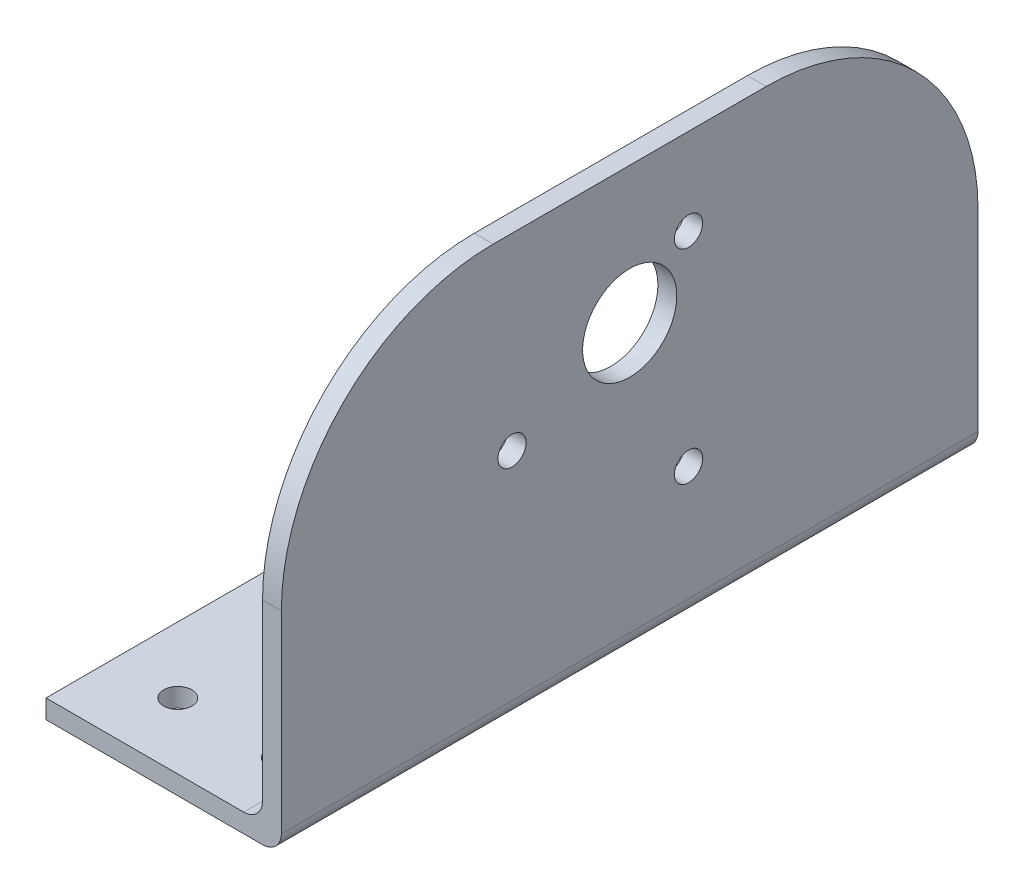
from build123d import *

# Parameters (mm, degrees)
BOSS_EXTRUDE1_DEPTH = 2
SKETCH2_W           = 74
SKETCH2_H           = 2
BOSS_EXTRUDE2_DEPTH = 23
FILLET1_R           = 2
SKETCH3_R           = 5
SKETCH3_R_2         = 1.5
CUT_EXTRUDE1_DEPTH  = 26
SKETCH5_R           = 1.5
CUT_EXTRUDE2_DEPTH  = 46


with BuildPart() as part:
    # Sketch1 → Boss-Extrude1 (new body)
    with BuildSketch(Plane(origin=(0, 0, 0), x_dir=(0, 0, -1), z_dir=(1, 0, 0))):
        with BuildLine():
            Line((-14.5, 45), (14.5, 45))
            ThreePointArc((14.5, 45), (30.409902577, 38.409902577), (37, 22.5))
            Line((37, 22.5), (37, 0))
            Line((37, 0), (-37, 0))
            Line((-37, 0), (-37, 22.5))
            ThreePointArc((-37, 22.5), (-30.409902577, 38.409902577), (-14.5, 45))
        make_face()
    extrude(amount=BOSS_EXTRUDE1_DEPTH)

    # Sketch2 → Boss-Extrude2 (add)
    with BuildSketch(Plane.ZY):
        with Locations((0, 1)):
            Rectangle(SKETCH2_W, SKETCH2_H)
    extrude(amount=BOSS_EXTRUDE2_DEPTH)

    # Fillet1
    fillet1_edges = [part.edges().sort_by_distance(p)[0] for p in [
        (2, 0, 0),
        (0, 2, 0),
    ]]
    fillet(fillet1_edges, radius=FILLET1_R)

    # Sketch3 → Cut-Extrude1 (cut, through all)
    with BuildSketch(Plane(origin=(2, 0, 0), x_dir=(0, 0, -1), z_dir=(1, 0, 0))):
        with Locations((0, 30.5)):
            Circle(SKETCH3_R)
        with Locations((6.25, 35.825317547)):
            Circle(SKETCH3_R_2)
        with Locations((6.25, 14.174682453)):
            Circle(SKETCH3_R_2)
        with Locations((-12.5, 25)):
            Circle(SKETCH3_R_2)
    extrude(amount=-CUT_EXTRUDE1_DEPTH, mode=Mode.SUBTRACT)

    # Sketch5 → Cut-Extrude2 (cut, through all)
    with BuildSketch(Plane.XZ):
        with Locations((-16, -30)):
            Circle(SKETCH5_R)
        with Locations((-5, -30)):
            Circle(SKETCH5_R)
        with Locations((-5, 30)):
            Circle(SKETCH5_R)
        with Locations((-16, 30)):
            Circle(SKETCH5_R)
    extrude(amount=-CUT_EXTRUDE2_DEPTH, mode=Mode.SUBTRACT)


solid = part.part
